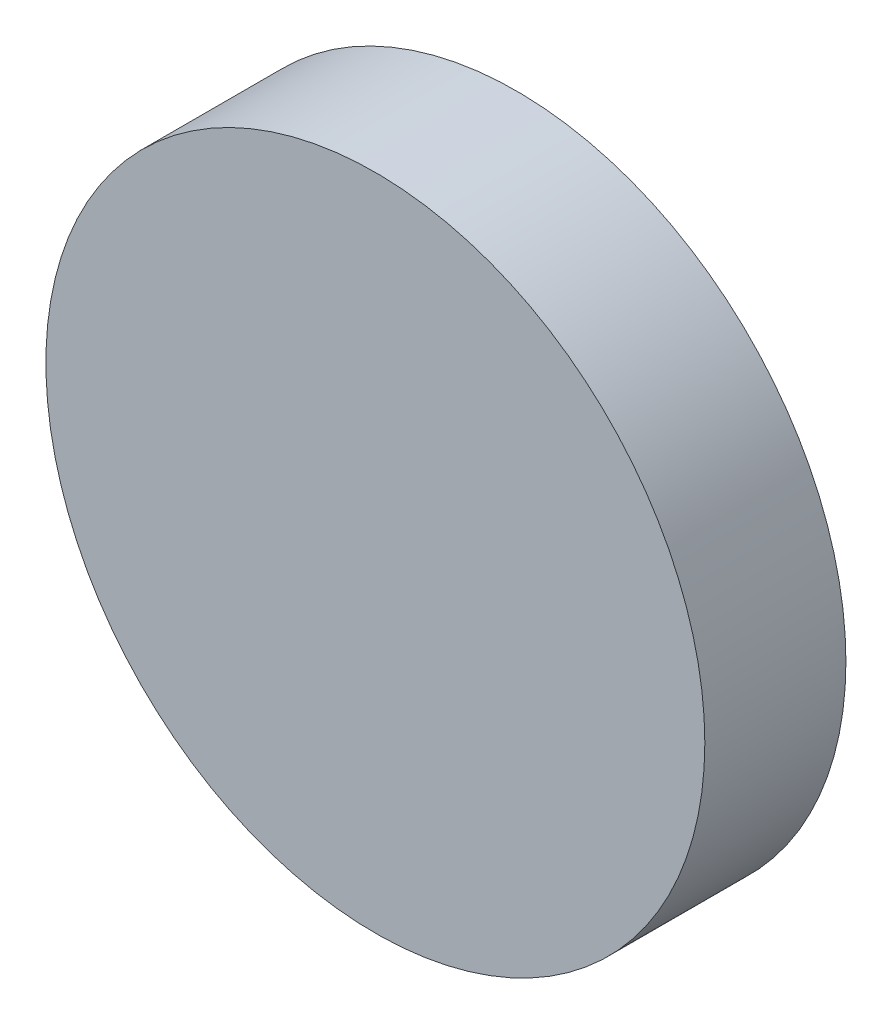
from build123d import *

# Parameters (mm, degrees)
SKETCH1_R           = 53.3821213
SKETCH1_R_2         = 50.8
BOSS_EXTRUDE1_DEPTH = 20.32
SKETCH2_R           = 53.3821213
BOSS_EXTRUDE2_DEPTH = 2.54


with BuildPart() as part:
    # Sketch1 → Boss-Extrude1 (new body)
    with BuildSketch(Plane.XY):
        with Locations((-17.698502245, 13.225254425)):
            Circle(SKETCH1_R)
        with Locations((-17.698502245, 13.225254425)):
            Circle(SKETCH1_R_2, mode=Mode.SUBTRACT)
    extrude(amount=BOSS_EXTRUDE1_DEPTH)

    # Sketch2 → Boss-Extrude2 (add)
    with BuildSketch(Plane.XY.offset(20.32)):
        with Locations((-17.698502245, 13.225254425)):
            Circle(SKETCH2_R)
    extrude(amount=BOSS_EXTRUDE2_DEPTH)


solid = part.part
